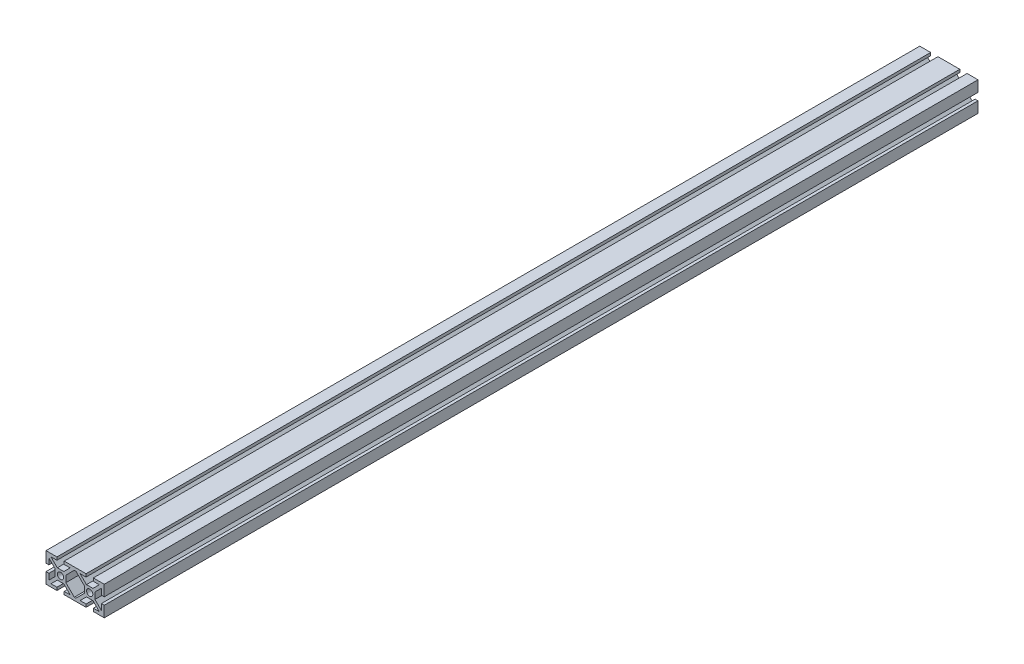
from build123d import *

# Parameters (mm, degrees)
ESQUISSE1_W        = 7.3
ESQUISSE1_H        = 7.3
ESQUISSE1_R        = 2.15
BOSS_EXTRU_2_DEPTH = 600


with BuildPart() as part:
    # Esquisse1 → Boss.-Extru.2 (new body)
    with BuildSketch(Plane.XY):
        Polygon((-8, -2.5), (-10, -2.5), (-10, -10), (-2.5, -10), (-2.5, -8), (-6.585786438, -8), (-2.235786438, -3.65), (-3.65, -3.65), (-3.65, -2.235786438), (-8, -6.585786438), align=None)
        Polygon((2.5, -8), (2.5, -10), (10, -10), (10, -8), (9.414213562, -8), (8, -6.585786438), (3.65, -2.235786438), (3.65, -3.65), (2.235786438, -3.65), (6.585786438, -8), align=None)
        Rectangle(ESQUISSE1_W, ESQUISSE1_H)
        Circle(ESQUISSE1_R, mode=Mode.SUBTRACT)
        Polygon((10, 10), (2.5, 10), (2.5, 8), (6.585786438, 8), (2.235786438, 3.65), (3.65, 3.65), (3.65, 2.235786438), (8, 6.585786438), (9.414213562, 8), (10, 8), align=None)
        Polygon((17.5, 10), (10, 10), (10, 8), (10.585786438, 8), (12, 6.585786438), (16.35, 2.235786438), (16.35, 3.65), (17.764213562, 3.65), (13.414213562, 8), (17.5, 8), align=None)
        Polygon((-2.5, 10), (-10, 10), (-10, 2.5), (-8, 2.5), (-8, 6.585786438), (-3.65, 2.235786438), (-3.65, 3.65), (-2.235786438, 3.65), (-6.585786438, 8), (-2.5, 8), align=None)
        Polygon((10, -8), (10, -10), (17.5, -10), (17.5, -8), (13.414213562, -8), (17.764213562, -3.65), (16.35, -3.65), (16.35, -2.235786438), (12, -6.585786438), (10.585786438, -8), align=None)
        Polygon((22.235786438, 3.65), (17.764213562, 3.65), (16.35, 3.65), (16.35, 2.235786438), (16.35, -2.235786438), (16.35, -3.65), (17.764213562, -3.65), (22.235786438, -3.65), (23.65, -3.65), (23.65, -2.235786438), (23.65, 2.235786438), (23.65, 3.65), align=None)
        with Locations((20, 0)):
            Circle(ESQUISSE1_R, mode=Mode.SUBTRACT)
        Polygon((30, 10), (22.5, 10), (22.5, 8), (26.585786438, 8), (22.235786438, 3.65), (23.65, 3.65), (23.65, 2.235786438), (28, 6.585786438), (28, 2.5), (30, 2.5), align=None)
        Polygon((30, -10), (30, -2.5), (28, -2.5), (28, -6.585786438), (23.65, -2.235786438), (23.65, -3.65), (22.235786438, -3.65), (26.585786438, -8), (22.5, -8), (22.5, -10), align=None)
    extrude(amount=BOSS_EXTRU_2_DEPTH)


solid = part.part
